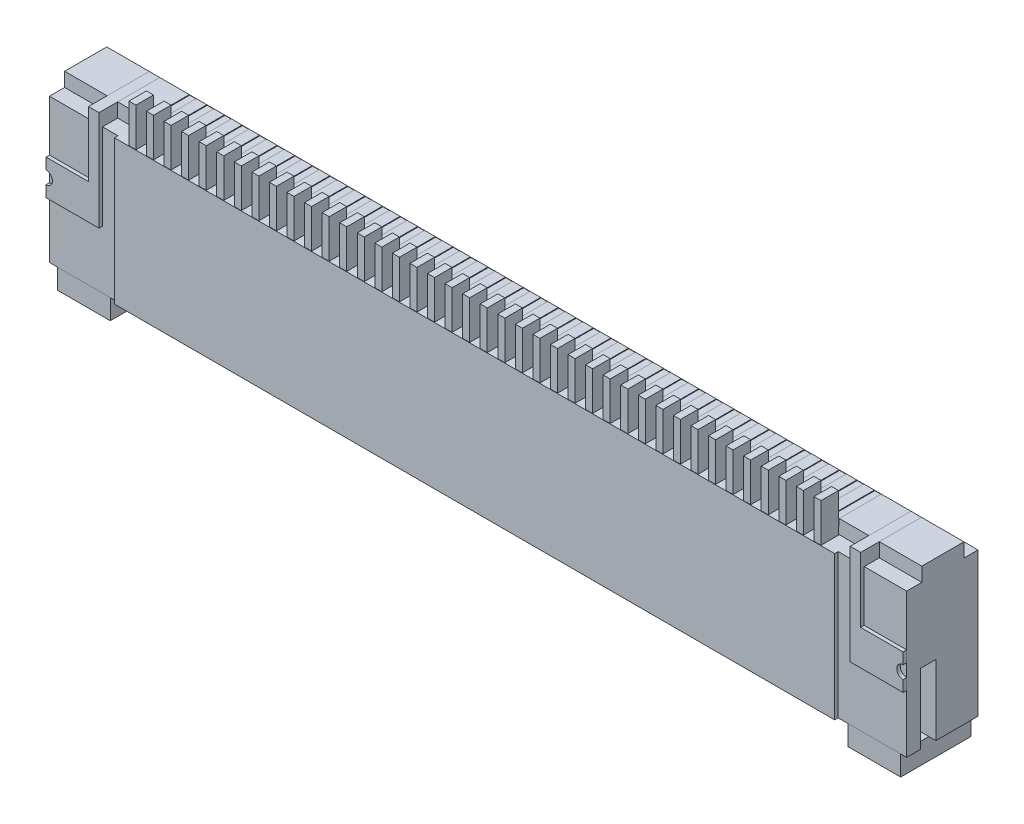
from build123d import *

# Parameters (mm, degrees)
ESBO_O1_W                 = 24.4
ESBO_O1_H                 = 4.5
RESSALTO_EXTRUS_O1_DEPTH  = 2.13
ESBO_O2_OUTSIDE_W         = 31.38
ESBO_O2_OUTSIDE_H         = 11.48
ESBO_O2_OUTSIDE_W_2       = 20.5
ESBO_O2_OUTSIDE_H_2       = 4.5
CORTE_EXTRUS_O1_DEPTH     = 0.1
CORTE_EXTRUS_O2_DEPTH     = 1.53
ESBO_O4_W                 = 0.43
ESBO_O4_H                 = 2
CORTE_EXTRUS_O3_DEPTH     = 25.4
ESBO_O5_W                 = 0.6
ESBO_O5_H                 = 1.7
RESSALTO_EXTRUS_O2_DEPTH  = 0.3
ESBO_O6_R                 = 0.2
CORTE_EXTRUS_O4_DEPTH     = 2
RESSALTO_EXTRUS_O3_START  = -0.03
RESSALTO_EXTRUS_O3_DEPTH  = 2
ESBO_O8_W                 = 20.674360077
ESBO_O8_H                 = 4.5
CORTE_EXTRUS_O5_DEPTH     = 3.13
ESBO_O10_W                = 21
ESBO_O10_H                = 1.4
CORTE_EXTRUS_O6_DEPTH     = 0.65
ESBO_O11_W                = 21
ESBO_O11_H                = 1.4
CORTE_EXTRUS_O7_DEPTH     = 6.1
RESSALTO_EXTRUS_O4_START  = 0.03
ESBO_O12_W                = 0.9
ESBO_O12_H                = 1.85
RESSALTO_EXTRUS_O4_DEPTH  = 1.3
ESBO_O13_W                = 20.9
ESBO_O13_H                = 0.3
RESSALTO_EXTRUS_O5_DEPTH  = 0.6
ESBO_O14_W                = 0.2
ESBO_O14_H                = 1.5
RESSALTO_EXTRUS_O6_DEPTH  = 0.5
PADR_O_LINEAR1_COUNT      = 40
PADR_O_LINEAR1_PITCH      = 0.5
RESSALTO_EXTRUS_O8_START  = -0.03
ESBO_O16_W                = 0.2
ESBO_O16_H                = 1.5
RESSALTO_EXTRUS_O8_DEPTH  = 0.5
ESBO_O17_W                = 0.8
ESBO_O17_H                = 0.8
ESBO_O17_W_2              = 0.86
CORTE_EXTRUS_O8_DEPTH     = 25.4
ESBO_O20_W                = 0.3
ESBO_O20_H                = 0.3
CORTE_EXTRUS_O9_DEPTH     = 10
ESBO_O19_W                = 1.209154669
ESBO_O19_H                = 1
RESSALTO_EXTRUS_O9_DEPTH  = 0.1
ESBO_O21_W                = 0.3
ESBO_O21_H                = 0.4
RESSALTO_EXTRUS_O10_DEPTH = 0.43
ESBO_O22_W                = 0.3
ESBO_O22_H                = 0.3
RESSALTO_EXTRUS_O11_DEPTH = 1.2
ESBO_O23_R                = 0.182878676
CORTE_EXTRUS_O10_DEPTH    = 10
RESSALTO_EXTRUS_O12_START = -0.01
ESBO_O24_W                = 0.2
ESBO_O24_H                = 1.1
RESSALTO_EXTRUS_O12_DEPTH = 0.5
PADR_O_LINEAR2_COUNT      = 40
PADR_O_LINEAR2_PITCH      = 0.5
ESBO_O25_W                = 0.2
ESBO_O25_H                = 1.22
CORTE_EXTRUS_O11_DEPTH    = 0.2
PADR_O_LINEAR3_COUNT      = 40
PADR_O_LINEAR3_PITCH      = 0.5
ESBO_O27_W                = 0.18
ESBO_O27_H                = 0.18
RESSALTO_EXTRUS_O14_DEPTH = 1.22
PADR_O_LINEAR4_COUNT      = 40
PADR_O_LINEAR4_PITCH      = 0.5


with BuildPart() as part:
    # Esboço1 → Ressalto-extrusão1 (new body)
    with BuildSketch(Plane.XY):
        Rectangle(ESBO_O1_W, ESBO_O1_H)
    extrude(amount=RESSALTO_EXTRUS_O1_DEPTH)

    # Esboço2 outside → Corte-extrusão1 (cut)
    with BuildSketch(Plane.XY.offset(2.13)):
        Rectangle(ESBO_O2_OUTSIDE_W, ESBO_O2_OUTSIDE_H)
        Rectangle(ESBO_O2_OUTSIDE_W_2, ESBO_O2_OUTSIDE_H_2, mode=Mode.SUBTRACT)
    extrude(amount=-CORTE_EXTRUS_O1_DEPTH, mode=Mode.SUBTRACT)

    # Esboço3 → Corte-extrusão2 (cut)
    with BuildSketch(Plane(origin=(0, 0, 0), x_dir=(-1, 0, 0), z_dir=(0, 0, -1))):
        Polygon((-11.5, -2.25), (-11.5, -0.25), (-10.3, -0.25), (-10.3, -0.75), (10.3, -0.75), (10.3, -0.25), (11.5, -0.25), (11.5, -2.25), align=None)
    extrude(amount=-CORTE_EXTRUS_O2_DEPTH, mode=Mode.SUBTRACT)

    # Esboço4 → Corte-extrusão3 (cut, through all)
    with BuildSketch(Plane.ZY.offset(12.2)):
        with Locations((1.415, -1.25)):
            Rectangle(ESBO_O4_W, ESBO_O4_H)
    extrude(amount=-CORTE_EXTRUS_O3_DEPTH, mode=Mode.SUBTRACT)

    # Esboço5 → Ressalto-extrusão2 (add)
    with BuildSketch(Plane(origin=(0, 0, 1.63), x_dir=(-1, 0, 0), z_dir=(0, 0, -1))):
        with Locations((10.9, -1.4)):
            Rectangle(ESBO_O5_W, ESBO_O5_H)
        with Locations((-10.9, -1.4)):
            Rectangle(ESBO_O5_W, ESBO_O5_H)
    extrude(amount=RESSALTO_EXTRUS_O2_DEPTH)

    # Esboço6 → Corte-extrusão4 (cut)
    with BuildSketch(Plane.XZ.offset(2.25)):
        with Locations((-11.5, 0.6)):
            Circle(ESBO_O6_R)
        with Locations((11.5, 0.6)):
            Circle(ESBO_O6_R)
    extrude(amount=-CORTE_EXTRUS_O4_DEPTH, mode=Mode.SUBTRACT)

    # Esboço17 → Corte-extrusão8 (cut, through all)
    with BuildSketch(Plane(origin=(12.2, 0, 0), x_dir=(0, 0, -1), z_dir=(1, 0, 0))):
        with Locations((0, 2.25)):
            Rectangle(ESBO_O17_W, ESBO_O17_H)
        with Locations((-2.03, 2.25)):
            Rectangle(ESBO_O17_W_2, ESBO_O17_H)
    extrude(amount=-CORTE_EXTRUS_O8_DEPTH, mode=Mode.SUBTRACT)

    # Esboço20 → Corte-extrusão9 (cut)
    with BuildSketch(Plane.XY.offset(1.6)):
        with Locations((-10.840845331, 2.1)):
            Rectangle(ESBO_O20_W, ESBO_O20_H)
    corte_extrus_o9 = extrude(amount=-CORTE_EXTRUS_O9_DEPTH, mode=Mode.SUBTRACT)

    # Espelhar1: Corte-extrusão9 across plane
    add(corte_extrus_o9.mirror(Plane(origin=(0, 0, 0), x_dir=(0, 0, 1), z_dir=(1, 0, 0))), mode=Mode.SUBTRACT)

    # Esboço24 → Ressalto-extrusão12 (add)
    with BuildSketch(Plane.XY.offset(2.13).offset(RESSALTO_EXTRUS_O12_START)):
        with Locations((-9.75, 2.4)):
            Rectangle(ESBO_O24_W, ESBO_O24_H)
    ressalto_extrus_o12 = extrude(amount=-RESSALTO_EXTRUS_O12_DEPTH)

    # Padrão linear2: Ressalto-extrusão12 ×40
    with Locations(*[(i * PADR_O_LINEAR2_PITCH, 0, 0) for i in range(1, PADR_O_LINEAR2_COUNT)]):
        add(ressalto_extrus_o12)

    # Esboço25 → Corte-extrusão11 (cut)
    with BuildSketch(Plane(origin=(0, 2.25, 0), x_dir=(1, 0, 0), z_dir=(0, 1, 0))):
        with Locations((-9.75, -1.01)):
            Rectangle(ESBO_O25_W, ESBO_O25_H)
    corte_extrus_o11 = extrude(amount=-CORTE_EXTRUS_O11_DEPTH, mode=Mode.SUBTRACT)

    # Padrão linear3: Corte-extrusão11 ×40
    with Locations(*[(i * PADR_O_LINEAR3_PITCH, 0, 0) for i in range(1, PADR_O_LINEAR3_COUNT)]):
        add(corte_extrus_o11, mode=Mode.SUBTRACT)

    # Esboço27 → Ressalto-extrusão14 (add)
    with BuildSketch(Plane(origin=(0, 0, 1.62), x_dir=(-1, 0, 0), z_dir=(0, 0, -1))):
        with Locations((9.75, 2.15)):
            Rectangle(ESBO_O27_W, ESBO_O27_H)
    ressalto_extrus_o14 = extrude(amount=RESSALTO_EXTRUS_O14_DEPTH)

    # Padrão linear4: Ressalto-extrusão14 ×40
    with Locations(*[(i * PADR_O_LINEAR4_PITCH, 0, 0) for i in range(1, PADR_O_LINEAR4_COUNT)]):
        add(ressalto_extrus_o14)


with BuildPart() as body_2:
    # Esboço7 → Ressalto-extrusão3 (new body)
    with BuildSketch(Plane.XY.offset(2.03).offset(RESSALTO_EXTRUS_O3_START)):
        Polygon((0, 2.25), (-10.25, 2.25), (-10.25, -2.25), (-12, -2.25), (-12, -2.85), (-10.5, -2.85), (-10, -3.5), (10, -3.5), (10.5, -2.85), (12, -2.85), (12, -2.25), (10.25, -2.25), (10.25, 2.25), align=None)
    extrude(amount=-RESSALTO_EXTRUS_O3_DEPTH)

    # Esboço8 → Corte-extrusão5 (cut, through all)
    with BuildSketch(Plane(origin=(0, 0, 0), x_dir=(-1, 0, 0), z_dir=(0, 0, -1))):
        with Locations((0.087180039, 0)):
            Rectangle(ESBO_O8_W, ESBO_O8_H)
    extrude(amount=-CORTE_EXTRUS_O5_DEPTH, mode=Mode.SUBTRACT)

    # Esboço10 → Corte-extrusão6 (cut)
    with BuildSketch(Plane.XZ.offset(3.5)):
        with Locations((0, 1.3)):
            Rectangle(ESBO_O10_W, ESBO_O10_H)
    extrude(amount=-CORTE_EXTRUS_O6_DEPTH, mode=Mode.SUBTRACT)

    # Esboço11 → Corte-extrusão7 (cut, through all)
    with BuildSketch(Plane.XZ.offset(2.85)):
        with Locations((0, 1.3)):
            Rectangle(ESBO_O11_W, ESBO_O11_H)
    extrude(amount=-CORTE_EXTRUS_O7_DEPTH, mode=Mode.SUBTRACT)

    # Esboço12 → Ressalto-extrusão4 (add)
    with BuildSketch(Plane(origin=(0, 0, 1.33), x_dir=(-1, 0, 0), z_dir=(0, 0, -1)).offset(RESSALTO_EXTRUS_O4_START)):
        with Locations((-10.9, -1.325)):
            Rectangle(ESBO_O12_W, ESBO_O12_H)
        with Locations((10.9, -1.325)):
            Rectangle(ESBO_O12_W, ESBO_O12_H)
    extrude(amount=RESSALTO_EXTRUS_O4_DEPTH)

    # Esboço13 → Ressalto-extrusão5 (add)
    with BuildSketch(Plane(origin=(0, 0, 0), x_dir=(-1, 0, 0), z_dir=(0, 0, -1))):
        with Locations((0, -2.1)):
            Rectangle(ESBO_O13_W, ESBO_O13_H)
    extrude(amount=-RESSALTO_EXTRUS_O5_DEPTH)

    # Esboço16 → Ressalto-extrusão8 (add)
    with BuildSketch(Plane(origin=(0, 0, 0), x_dir=(-1, 0, 0), z_dir=(0, 0, -1)).offset(RESSALTO_EXTRUS_O8_START)):
        with Locations((-9.75, -1.5)):
            Rectangle(ESBO_O16_W, ESBO_O16_H)
        with Locations((-9.25, -1.5)):
            Rectangle(ESBO_O16_W, ESBO_O16_H)
        with Locations((-8.75, -1.5)):
            Rectangle(ESBO_O16_W, ESBO_O16_H)
        with Locations((-8.25, -1.5)):
            Rectangle(ESBO_O16_W, ESBO_O16_H)
        with Locations((-7.75, -1.5)):
            Rectangle(ESBO_O16_W, ESBO_O16_H)
        with Locations((-7.25, -1.5)):
            Rectangle(ESBO_O16_W, ESBO_O16_H)
        with Locations((-6.75, -1.5)):
            Rectangle(ESBO_O16_W, ESBO_O16_H)
        with Locations((-6.25, -1.5)):
            Rectangle(ESBO_O16_W, ESBO_O16_H)
        with Locations((-5.75, -1.5)):
            Rectangle(ESBO_O16_W, ESBO_O16_H)
        with Locations((-5.25, -1.5)):
            Rectangle(ESBO_O16_W, ESBO_O16_H)
        with Locations((-4.75, -1.5)):
            Rectangle(ESBO_O16_W, ESBO_O16_H)
        with Locations((-4.25, -1.5)):
            Rectangle(ESBO_O16_W, ESBO_O16_H)
        with Locations((-3.75, -1.5)):
            Rectangle(ESBO_O16_W, ESBO_O16_H)
        with Locations((-3.25, -1.5)):
            Rectangle(ESBO_O16_W, ESBO_O16_H)
        with Locations((-2.75, -1.5)):
            Rectangle(ESBO_O16_W, ESBO_O16_H)
        with Locations((-2.25, -1.5)):
            Rectangle(ESBO_O16_W, ESBO_O16_H)
        with Locations((-1.75, -1.5)):
            Rectangle(ESBO_O16_W, ESBO_O16_H)
        with Locations((-1.25, -1.5)):
            Rectangle(ESBO_O16_W, ESBO_O16_H)
        with Locations((-0.75, -1.5)):
            Rectangle(ESBO_O16_W, ESBO_O16_H)
        with Locations((-0.25, -1.5)):
            Rectangle(ESBO_O16_W, ESBO_O16_H)
        with Locations((0.25, -1.5)):
            Rectangle(ESBO_O16_W, ESBO_O16_H)
        with Locations((0.75, -1.5)):
            Rectangle(ESBO_O16_W, ESBO_O16_H)
        with Locations((1.25, -1.5)):
            Rectangle(ESBO_O16_W, ESBO_O16_H)
        with Locations((1.75, -1.5)):
            Rectangle(ESBO_O16_W, ESBO_O16_H)
        with Locations((2.25, -1.5)):
            Rectangle(ESBO_O16_W, ESBO_O16_H)
        with Locations((2.75, -1.5)):
            Rectangle(ESBO_O16_W, ESBO_O16_H)
        with Locations((3.25, -1.5)):
            Rectangle(ESBO_O16_W, ESBO_O16_H)
        with Locations((3.75, -1.5)):
            Rectangle(ESBO_O16_W, ESBO_O16_H)
        with Locations((4.25, -1.5)):
            Rectangle(ESBO_O16_W, ESBO_O16_H)
        with Locations((4.75, -1.5)):
            Rectangle(ESBO_O16_W, ESBO_O16_H)
        with Locations((5.25, -1.5)):
            Rectangle(ESBO_O16_W, ESBO_O16_H)
        with Locations((5.75, -1.5)):
            Rectangle(ESBO_O16_W, ESBO_O16_H)
        with Locations((6.25, -1.5)):
            Rectangle(ESBO_O16_W, ESBO_O16_H)
        with Locations((6.75, -1.5)):
            Rectangle(ESBO_O16_W, ESBO_O16_H)
        with Locations((7.25, -1.5)):
            Rectangle(ESBO_O16_W, ESBO_O16_H)
        with Locations((7.75, -1.5)):
            Rectangle(ESBO_O16_W, ESBO_O16_H)
        with Locations((8.25, -1.5)):
            Rectangle(ESBO_O16_W, ESBO_O16_H)
        with Locations((8.75, -1.5)):
            Rectangle(ESBO_O16_W, ESBO_O16_H)
        with Locations((9.25, -1.5)):
            Rectangle(ESBO_O16_W, ESBO_O16_H)
        with Locations((9.75, -1.5)):
            Rectangle(ESBO_O16_W, ESBO_O16_H)
    extrude(amount=-RESSALTO_EXTRUS_O8_DEPTH)


with BuildPart() as body_3:
    # Esboço14 → Ressalto-extrusão6 (new body)
    with BuildSketch(Plane(origin=(0, 0, 1.63), x_dir=(-1, 0, 0), z_dir=(0, 0, -1))):
        with Locations((-9.75, -1.5)):
            Rectangle(ESBO_O14_W, ESBO_O14_H)
    extrude(amount=RESSALTO_EXTRUS_O6_DEPTH)


with BuildPart() as padr_o_linear1_1:
    # Padrão linear1: pattern copy
    add(body_3.part.moved(Location(Vector(-1, 0, 0) * (1 * PADR_O_LINEAR1_PITCH))))


with BuildPart() as padr_o_linear1_2:
    # Padrão linear1: pattern copy
    add(body_3.part.moved(Location(Vector(-1, 0, 0) * (2 * PADR_O_LINEAR1_PITCH))))


with BuildPart() as padr_o_linear1_3:
    # Padrão linear1: pattern copy
    add(body_3.part.moved(Location(Vector(-1, 0, 0) * (3 * PADR_O_LINEAR1_PITCH))))


with BuildPart() as padr_o_linear1_4:
    # Padrão linear1: pattern copy
    add(body_3.part.moved(Location(Vector(-1, 0, 0) * (4 * PADR_O_LINEAR1_PITCH))))


with BuildPart() as padr_o_linear1_5:
    # Padrão linear1: pattern copy
    add(body_3.part.moved(Location(Vector(-1, 0, 0) * (5 * PADR_O_LINEAR1_PITCH))))


with BuildPart() as padr_o_linear1_6:
    # Padrão linear1: pattern copy
    add(body_3.part.moved(Location(Vector(-1, 0, 0) * (6 * PADR_O_LINEAR1_PITCH))))


with BuildPart() as padr_o_linear1_7:
    # Padrão linear1: pattern copy
    add(body_3.part.moved(Location(Vector(-1, 0, 0) * (7 * PADR_O_LINEAR1_PITCH))))


with BuildPart() as padr_o_linear1_8:
    # Padrão linear1: pattern copy
    add(body_3.part.moved(Location(Vector(-1, 0, 0) * (8 * PADR_O_LINEAR1_PITCH))))


with BuildPart() as padr_o_linear1_9:
    # Padrão linear1: pattern copy
    add(body_3.part.moved(Location(Vector(-1, 0, 0) * (9 * PADR_O_LINEAR1_PITCH))))


with BuildPart() as padr_o_linear1_10:
    # Padrão linear1: pattern copy
    add(body_3.part.moved(Location(Vector(-1, 0, 0) * (10 * PADR_O_LINEAR1_PITCH))))


with BuildPart() as padr_o_linear1_11:
    # Padrão linear1: pattern copy
    add(body_3.part.moved(Location(Vector(-1, 0, 0) * (11 * PADR_O_LINEAR1_PITCH))))


with BuildPart() as padr_o_linear1_12:
    # Padrão linear1: pattern copy
    add(body_3.part.moved(Location(Vector(-1, 0, 0) * (12 * PADR_O_LINEAR1_PITCH))))


with BuildPart() as padr_o_linear1_13:
    # Padrão linear1: pattern copy
    add(body_3.part.moved(Location(Vector(-1, 0, 0) * (13 * PADR_O_LINEAR1_PITCH))))


with BuildPart() as padr_o_linear1_14:
    # Padrão linear1: pattern copy
    add(body_3.part.moved(Location(Vector(-1, 0, 0) * (14 * PADR_O_LINEAR1_PITCH))))


with BuildPart() as padr_o_linear1_15:
    # Padrão linear1: pattern copy
    add(body_3.part.moved(Location(Vector(-1, 0, 0) * (15 * PADR_O_LINEAR1_PITCH))))


with BuildPart() as padr_o_linear1_16:
    # Padrão linear1: pattern copy
    add(body_3.part.moved(Location(Vector(-1, 0, 0) * (16 * PADR_O_LINEAR1_PITCH))))


with BuildPart() as padr_o_linear1_17:
    # Padrão linear1: pattern copy
    add(body_3.part.moved(Location(Vector(-1, 0, 0) * (17 * PADR_O_LINEAR1_PITCH))))


with BuildPart() as padr_o_linear1_18:
    # Padrão linear1: pattern copy
    add(body_3.part.moved(Location(Vector(-1, 0, 0) * (18 * PADR_O_LINEAR1_PITCH))))


with BuildPart() as padr_o_linear1_19:
    # Padrão linear1: pattern copy
    add(body_3.part.moved(Location(Vector(-1, 0, 0) * (19 * PADR_O_LINEAR1_PITCH))))


with BuildPart() as padr_o_linear1_20:
    # Padrão linear1: pattern copy
    add(body_3.part.moved(Location(Vector(-1, 0, 0) * (20 * PADR_O_LINEAR1_PITCH))))


with BuildPart() as padr_o_linear1_21:
    # Padrão linear1: pattern copy
    add(body_3.part.moved(Location(Vector(-1, 0, 0) * (21 * PADR_O_LINEAR1_PITCH))))


with BuildPart() as padr_o_linear1_22:
    # Padrão linear1: pattern copy
    add(body_3.part.moved(Location(Vector(-1, 0, 0) * (22 * PADR_O_LINEAR1_PITCH))))


with BuildPart() as padr_o_linear1_23:
    # Padrão linear1: pattern copy
    add(body_3.part.moved(Location(Vector(-1, 0, 0) * (23 * PADR_O_LINEAR1_PITCH))))


with BuildPart() as padr_o_linear1_24:
    # Padrão linear1: pattern copy
    add(body_3.part.moved(Location(Vector(-1, 0, 0) * (24 * PADR_O_LINEAR1_PITCH))))


with BuildPart() as padr_o_linear1_25:
    # Padrão linear1: pattern copy
    add(body_3.part.moved(Location(Vector(-1, 0, 0) * (25 * PADR_O_LINEAR1_PITCH))))


with BuildPart() as padr_o_linear1_26:
    # Padrão linear1: pattern copy
    add(body_3.part.moved(Location(Vector(-1, 0, 0) * (26 * PADR_O_LINEAR1_PITCH))))


with BuildPart() as padr_o_linear1_27:
    # Padrão linear1: pattern copy
    add(body_3.part.moved(Location(Vector(-1, 0, 0) * (27 * PADR_O_LINEAR1_PITCH))))


with BuildPart() as padr_o_linear1_28:
    # Padrão linear1: pattern copy
    add(body_3.part.moved(Location(Vector(-1, 0, 0) * (28 * PADR_O_LINEAR1_PITCH))))


with BuildPart() as padr_o_linear1_29:
    # Padrão linear1: pattern copy
    add(body_3.part.moved(Location(Vector(-1, 0, 0) * (29 * PADR_O_LINEAR1_PITCH))))


with BuildPart() as padr_o_linear1_30:
    # Padrão linear1: pattern copy
    add(body_3.part.moved(Location(Vector(-1, 0, 0) * (30 * PADR_O_LINEAR1_PITCH))))


with BuildPart() as padr_o_linear1_31:
    # Padrão linear1: pattern copy
    add(body_3.part.moved(Location(Vector(-1, 0, 0) * (31 * PADR_O_LINEAR1_PITCH))))


with BuildPart() as padr_o_linear1_32:
    # Padrão linear1: pattern copy
    add(body_3.part.moved(Location(Vector(-1, 0, 0) * (32 * PADR_O_LINEAR1_PITCH))))


with BuildPart() as padr_o_linear1_33:
    # Padrão linear1: pattern copy
    add(body_3.part.moved(Location(Vector(-1, 0, 0) * (33 * PADR_O_LINEAR1_PITCH))))


with BuildPart() as padr_o_linear1_34:
    # Padrão linear1: pattern copy
    add(body_3.part.moved(Location(Vector(-1, 0, 0) * (34 * PADR_O_LINEAR1_PITCH))))


with BuildPart() as padr_o_linear1_35:
    # Padrão linear1: pattern copy
    add(body_3.part.moved(Location(Vector(-1, 0, 0) * (35 * PADR_O_LINEAR1_PITCH))))


with BuildPart() as padr_o_linear1_36:
    # Padrão linear1: pattern copy
    add(body_3.part.moved(Location(Vector(-1, 0, 0) * (36 * PADR_O_LINEAR1_PITCH))))


with BuildPart() as padr_o_linear1_37:
    # Padrão linear1: pattern copy
    add(body_3.part.moved(Location(Vector(-1, 0, 0) * (37 * PADR_O_LINEAR1_PITCH))))


with BuildPart() as padr_o_linear1_38:
    # Padrão linear1: pattern copy
    add(body_3.part.moved(Location(Vector(-1, 0, 0) * (38 * PADR_O_LINEAR1_PITCH))))


with BuildPart() as padr_o_linear1_39:
    # Padrão linear1: pattern copy
    add(body_3.part.moved(Location(Vector(-1, 0, 0) * (39 * PADR_O_LINEAR1_PITCH))))


with BuildPart() as body_43:
    # Esboço19 → Ressalto-extrusão9 (new body)
    with BuildSketch(Plane.XY.offset(2.13)):
        with Locations((-11.595422666, -0.1)):
            Rectangle(ESBO_O19_W, ESBO_O19_H)
        Polygon((-10.990845331, 2.25), (-10.990845331, 0.4), (-10.990845331, -0.6), (-10.690845331, -0.6), (-10.690845331, 2.25), align=None)
    extrude(amount=-RESSALTO_EXTRUS_O9_DEPTH)

    # Esboço21 → Ressalto-extrusão10 (add)
    with BuildSketch(Plane(origin=(0, 0, 2.03), x_dir=(-1, 0, 0), z_dir=(0, 0, -1))):
        with Locations((10.840845331, 2.05)):
            Rectangle(ESBO_O21_W, ESBO_O21_H)
    extrude(amount=RESSALTO_EXTRUS_O10_DEPTH)

    # Esboço22 → Ressalto-extrusão11 (add)
    with BuildSketch(Plane(origin=(0, 0, 1.6), x_dir=(-1, 0, 0), z_dir=(0, 0, -1))):
        with Locations((10.840845331, 2.1)):
            Rectangle(ESBO_O22_W, ESBO_O22_H)
    extrude(amount=RESSALTO_EXTRUS_O11_DEPTH)

    # Esboço23 → Corte-extrusão10 (cut)
    with BuildSketch(Plane.XY.offset(2.13)):
        with Locations((-12.2, -0.1)):
            Circle(ESBO_O23_R)
    extrude(amount=-CORTE_EXTRUS_O10_DEPTH, mode=Mode.SUBTRACT)


with BuildPart() as body_44:
    # Espelhar2: mirrored copy
    add(body_43.part.mirror(Plane(origin=(0, 0, 0), x_dir=(0, 0, 1), z_dir=(1, 0, 0))))


solid = Compound([part.part, body_2.part, body_3.part, padr_o_linear1_1.part, padr_o_linear1_2.part, padr_o_linear1_3.part, padr_o_linear1_4.part, padr_o_linear1_5.part, padr_o_linear1_6.part, padr_o_linear1_7.part, padr_o_linear1_8.part, padr_o_linear1_9.part, padr_o_linear1_10.part, padr_o_linear1_11.part, padr_o_linear1_12.part, padr_o_linear1_13.part, padr_o_linear1_14.part, padr_o_linear1_15.part, padr_o_linear1_16.part, padr_o_linear1_17.part, padr_o_linear1_18.part, padr_o_linear1_19.part, padr_o_linear1_20.part, padr_o_linear1_21.part, padr_o_linear1_22.part, padr_o_linear1_23.part, padr_o_linear1_24.part, padr_o_linear1_25.part, padr_o_linear1_26.part, padr_o_linear1_27.part, padr_o_linear1_28.part, padr_o_linear1_29.part, padr_o_linear1_30.part, padr_o_linear1_31.part, padr_o_linear1_32.part, padr_o_linear1_33.part, padr_o_linear1_34.part, padr_o_linear1_35.part, padr_o_linear1_36.part, padr_o_linear1_37.part, padr_o_linear1_38.part, padr_o_linear1_39.part, body_43.part, body_44.part])
